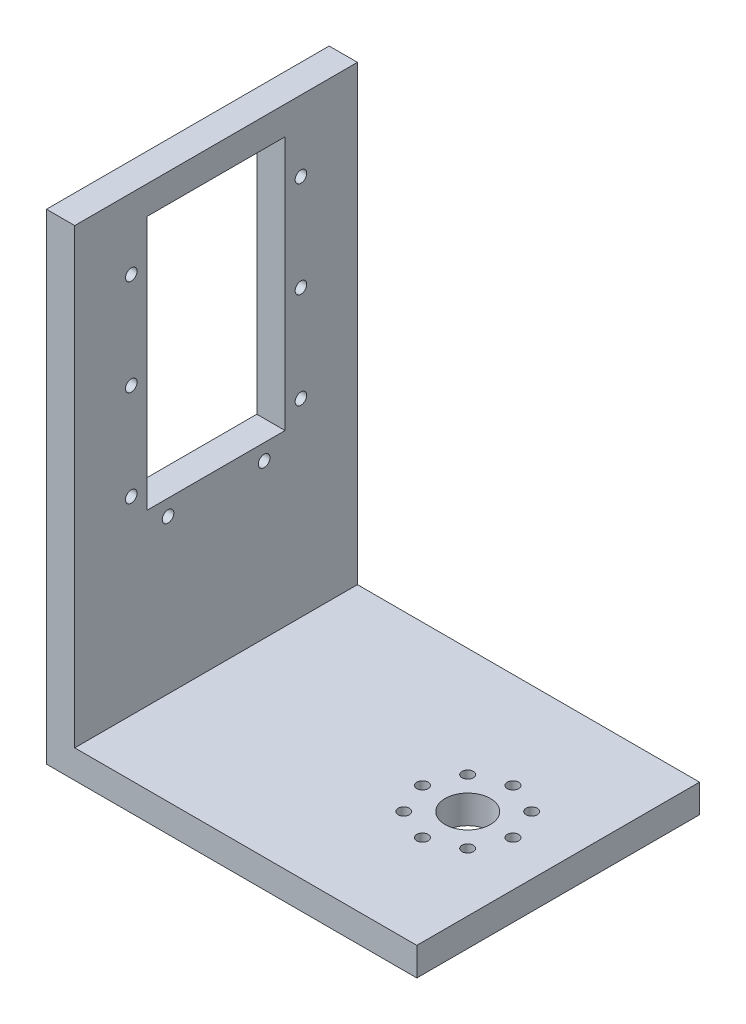
from build123d import *

# Parameters (mm, degrees)
SKETCH1_W           = 65.5
SKETCH1_H           = 50
SKETCH1_R           = 4
SKETCH1_R_2         = 1
BOSS_EXTRUDE1_DEPTH = 5
SKETCH3_W           = 5
SKETCH3_H           = 50
BOSS_EXTRUDE2_DEPTH = 85
SKETCH4_R           = 1.025
SKETCH4_W           = 24.4
SKETCH4_H           = 45
CUT_EXTRUDE1_DEPTH  = 66.5


with BuildPart() as part:
    # Sketch1 → Boss-Extrude1 (new body)
    with BuildSketch(Plane(origin=(0, 0, 0), x_dir=(1, 0, 0), z_dir=(0, 1, 0))):
        with Locations((32.75, 25)):
            Rectangle(SKETCH1_W, SKETCH1_H)
        with Locations((49.5, 25)):
            Circle(SKETCH1_R, mode=Mode.SUBTRACT)
        with Locations((49.5, 33)):
            Circle(SKETCH1_R_2, mode=Mode.SUBTRACT)
        with Locations((55.156854249, 30.656854249)):
            Circle(SKETCH1_R_2, mode=Mode.SUBTRACT)
        with Locations((57.5, 25)):
            Circle(SKETCH1_R_2, mode=Mode.SUBTRACT)
        with Locations((55.156854249, 19.343145751)):
            Circle(SKETCH1_R_2, mode=Mode.SUBTRACT)
        with Locations((49.5, 17)):
            Circle(SKETCH1_R_2, mode=Mode.SUBTRACT)
        with Locations((43.843145751, 19.343145751)):
            Circle(SKETCH1_R_2, mode=Mode.SUBTRACT)
        with Locations((41.5, 25)):
            Circle(SKETCH1_R_2, mode=Mode.SUBTRACT)
        with Locations((43.843145751, 30.656854249)):
            Circle(SKETCH1_R_2, mode=Mode.SUBTRACT)
    extrude(amount=BOSS_EXTRUDE1_DEPTH)

    # Sketch3 → Boss-Extrude2 (add)
    with BuildSketch(Plane(origin=(0, 0, 0), x_dir=(1, 0, 0), z_dir=(0, 1, 0))):
        with Locations((2.5, 25)):
            Rectangle(SKETCH3_W, SKETCH3_H)
    extrude(amount=BOSS_EXTRUDE2_DEPTH)

    # Sketch4 → Cut-Extrude1 (cut, through all)
    with BuildSketch(Plane.ZY):
        with Locations((-40, 72.5)):
            Circle(SKETCH4_R)
        with Locations((-10, 72.5)):
            Circle(SKETCH4_R)
        with Locations((-40, 55.5)):
            Circle(SKETCH4_R)
        with Locations((-40, 38.5)):
            Circle(SKETCH4_R)
        with Locations((-10, 55.5)):
            Circle(SKETCH4_R)
        with Locations((-33.5, 32.2)):
            Circle(SKETCH4_R)
        with Locations((-16.5, 32.2)):
            Circle(SKETCH4_R)
        with Locations((-10, 38.5)):
            Circle(SKETCH4_R)
        with Locations((-25, 57.5)):
            Rectangle(SKETCH4_W, SKETCH4_H)
    extrude(amount=-CUT_EXTRUDE1_DEPTH, mode=Mode.SUBTRACT)


solid = part.part
